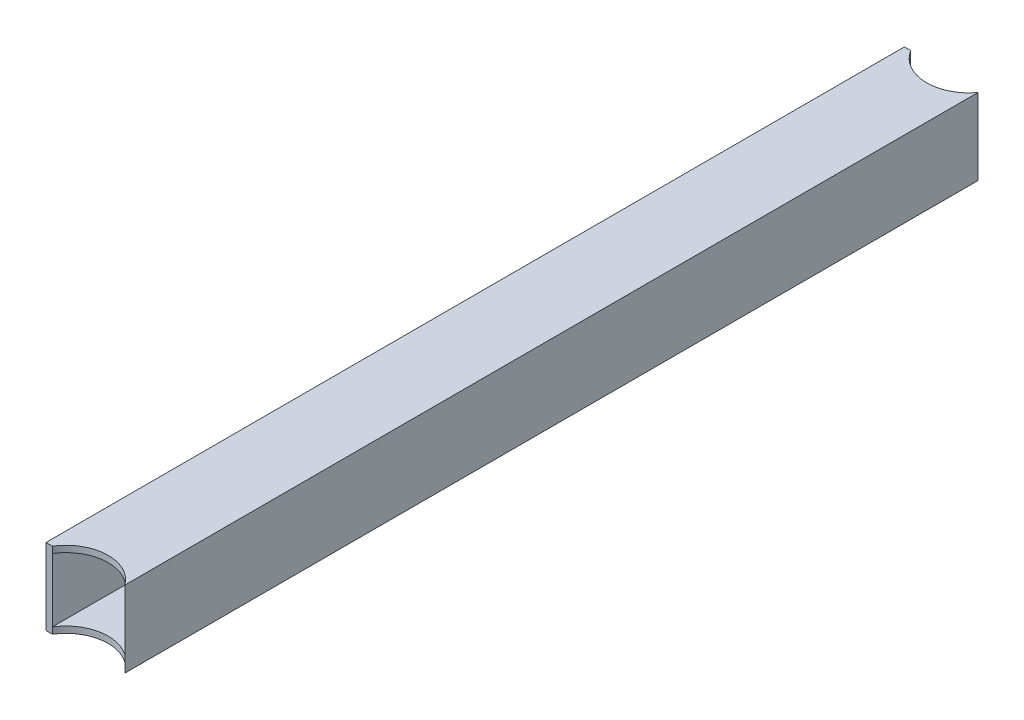
from build123d import *

# Parameters (mm, degrees)
SKETCH2_W                = 38.1
SKETCH2_H                = 38.1
SKETCH2_W_2              = 31.75
SKETCH2_H_2              = 31.75
BOSS_EXTRUDE1_DEPTH      = 762
BOSS_EXTRUDE1_DEPTH_BACK = 762
SKETCH3_R                = 21.082
CUT_EXTRUDE1_DEPTH       = 764.902624685
CUT_EXTRUDE2_DEPTH       = 232.775000254


with BuildPart() as part:
    # Sketch2 → Boss-Extrude1 (new, two sides)
    with BuildSketch(Plane.XY) as boss_extrude1_sk:
        with Locations((19.05, 19.05)):
            Rectangle(SKETCH2_W, SKETCH2_H)
        with Locations((19.05, 19.05)):
            Rectangle(SKETCH2_W_2, SKETCH2_H_2, mode=Mode.SUBTRACT)
    extrude(amount=BOSS_EXTRUDE1_DEPTH)
    extrude(boss_extrude1_sk.sketch, amount=-BOSS_EXTRUDE1_DEPTH_BACK)

    # Sketch3 → Cut-Extrude1 (cut, through all)
    with BuildSketch(Plane(origin=(0, 38.1, 0), x_dir=(1, 0, 0), z_dir=(0, 1, 0))):
        with Locations((21.082, -225.425)):
            Circle(SKETCH3_R)
        with Locations((21.082, 225.425)):
            Circle(SKETCH3_R)
    extrude(amount=-CUT_EXTRUDE1_DEPTH, mode=Mode.SUBTRACT)


with BuildPart() as cut_extrude1_kept_piece:
    # of the separate pieces the step leaves, the one the design keeps (cut_extrude1_pieces_kept)
    add(part.part.solids().sort_by_distance((38.1, 38.1, 212.981592107))[0])

    # Sketch4 → Cut-Extrude2 (cut, through all)
    with BuildSketch(Plane(origin=(0, 38.1, 0), x_dir=(1, 0, 0), z_dir=(0, 1, 0))):
        with BuildLine():
            Line((0, -214.3125), (0, -225.425))
            ThreePointArc((0, -225.425), (0.807088464, -219.647570969), (3.166557841, -214.3125))
            Line((3.166557841, -214.3125), (0, -214.3125))
        make_face()
        with BuildLine():
            Line((0, 225.425), (0, 214.3125))
            Line((0, 214.3125), (3.166557841, 214.3125))
            ThreePointArc((3.166557841, 214.3125), (0.807088464, 219.647570969), (0, 225.425))
        make_face()
    extrude(amount=-CUT_EXTRUDE2_DEPTH, mode=Mode.SUBTRACT)


solid = cut_extrude1_kept_piece.part
